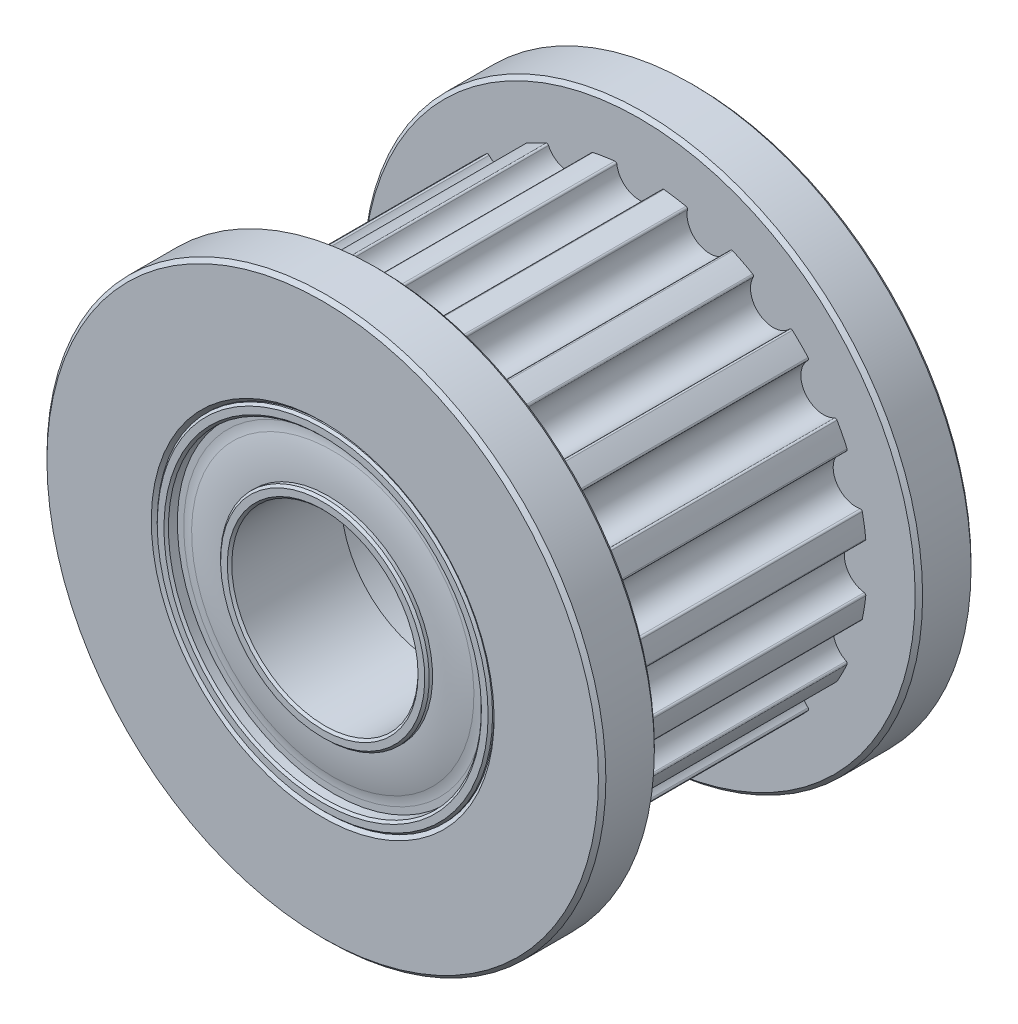
from build123d import *

# Parameters (mm, degrees)
CHAMFER2_SIZE            = 0.06
FILLET2_R                = 1
CHAMFER1_SIZE            = 0.1
CUT_EXTRUDE1_DEPTH       = 3.5
FILLET1_R                = 0.05
CIRPATTERN3_COUNT        = 20
FILLET1_OF_CIRPATTERN3_R = 0.05


with BuildPart() as part:
    # Sketch2 → Revolve1 (revolve)
    with BuildSketch(Plane(origin=(0, 0, 0), x_dir=(0, 0, -1), z_dir=(1, 0, 0))):
        with BuildLine():
            Line((5, 2.5), (2, 2.5))
            Line((2, 2.5), (2, 4.5))
            Line((2, 4.5), (5, 4.5))
            Line((5, 4.5), (5, 4.2))
            Line((5, 4.2), (4.7, 4.2))
            Line((4.7, 4.2), (4.7, 3.9))
            ThreePointArc((4.7, 3.9), (4.812327274, 3.355090083), (4.85, 2.8))
            Line((4.85, 2.8), (5, 2.8))
            Line((5, 2.8), (5, 2.5))
        make_face()
    revolve(axis=Axis((0, 0, 5), (0, 0, -1)))

    # Chamfer2
    chamfer2_edges = [part.edges().sort_by_distance(p)[0] for p in [
        (0, -2.5, -5),
        (0, -2.8, -5),
        (0, -4.2, -5),
        (0, -4.5, -5),
    ]]
    chamfer(chamfer2_edges, length=CHAMFER2_SIZE)

    # Fillet2
    fillet2_edges = [part.edges().sort_by_distance(p)[0] for p in [
        (0, -3.9, -4.7),
    ]]
    fillet(fillet2_edges, radius=FILLET2_R)


with BuildPart() as body_2:
    # Mirror1: mirrored copy
    add(part.part.mirror(Plane.XY))


with BuildPart() as body_3:
    # Sketch3 → Revolve2 (revolve)
    with BuildSketch(Plane(origin=(0, 0, 0), x_dir=(0, 0, -1), z_dir=(1, 0, 0))):
        Polygon((3.5, 7.5), (5, 7.5), (5, 4.5), (2, 4.5), (2, 3.5), (-2, 3.5), (-2, 4.5), (-5, 4.5), (-5, 7.5), (-3.5, 7.5), (-3.5, 6.11), (3.5, 6.11), align=None)
    revolve(axis=Axis((0, 0, 5), (0, 0, -1)))

    # Chamfer1
    chamfer1_edges = [body_3.edges().sort_by_distance(p)[0] for p in [
        (0, -4.5, 5),
        (0, -4.5, -5),
        (0, -7.5, -5),
        (0, -7.5, -3.5),
        (0, -7.5, 3.5),
        (0, -7.5, 5),
    ]]
    chamfer(chamfer1_edges, length=CHAMFER1_SIZE)

    # Sketch4 → Cut-Extrude1 (cut, symmetric)
    with BuildSketch(Plane.XY):
        with BuildLine():
            Line((-0.611, 6.11), (0.611, 6.11))
            ThreePointArc((0.611, 6.11), (0, 5.499), (-0.611, 6.11))
        make_face()
    cut_extrude1 = extrude(amount=CUT_EXTRUDE1_DEPTH, both=True, mode=Mode.SUBTRACT)

    # Fillet1
    fillet1_edges = [body_3.edges().sort_by_distance(p)[0] for p in [
        (0.610235772, 6.07945, 0),
        (-0.610235772, 6.07945, 0),
    ]]
    fillet(fillet1_edges, radius=FILLET1_R)

    # CirPattern3: Cut-Extrude1 ×20 about axis
    cirpattern3_axis = Axis((0, 0, 0), (0, 0, 1))
    for i in range(1, CIRPATTERN3_COUNT):
        add(cut_extrude1.rotate(cirpattern3_axis, i * 360 / CIRPATTERN3_COUNT), mode=Mode.SUBTRACT)

    # Fillet1 of CirPattern3
    fillet1_of_cirpattern3_edges = [body_3.edges().sort_by_distance(p)[0] for p in [
        (-1.298284659, 5.970473762, 0),
        (-2.459022074, 5.593327314, 0),
        (-3.079719942, 5.277065954, 0),
        (-4.067102162, 4.559690779, 0),
        (-4.559690779, 4.067102162, 0),
        (-5.277065954, 3.079719942, 0),
        (-5.593327314, 2.459022074, 0),
        (-5.970473762, 1.298284659, 0),
        (-6.07945, 0.610235772, 0),
        (-6.07945, -0.610235772, 0),
        (-5.970473762, -1.298284659, 0),
        (-5.593327314, -2.459022074, 0),
        (-5.277065954, -3.079719942, 0),
        (-4.559690779, -4.067102162, 0),
        (-4.067102162, -4.559690779, 0),
        (-3.079719942, -5.277065954, 0),
        (-2.459022074, -5.593327314, 0),
        (-1.298284659, -5.970473762, 0),
        (-0.610235772, -6.07945, 0),
        (0.610235772, -6.07945, 0),
        (1.298284659, -5.970473762, 0),
        (2.459022074, -5.593327314, 0),
        (3.079719942, -5.277065954, 0),
        (4.067102162, -4.559690779, 0),
        (4.559690779, -4.067102162, 0),
        (5.277065954, -3.079719942, 0),
        (5.593327314, -2.459022074, 0),
        (5.970473762, -1.298284659, 0),
        (6.07945, -0.610235772, 0),
        (6.07945, 0.610235772, 0),
        (5.970473762, 1.298284659, 0),
        (5.593327314, 2.459022074, 0),
        (5.277065954, 3.079719942, 0),
        (4.559690779, 4.067102162, 0),
        (4.067102162, 4.559690779, 0),
        (3.079719942, 5.277065954, 0),
        (2.459022074, 5.593327314, 0),
        (1.298284659, 5.970473762, 0),
    ]]
    fillet(fillet1_of_cirpattern3_edges, radius=FILLET1_OF_CIRPATTERN3_R)


solid = Compound([part.part, body_2.part, body_3.part])
